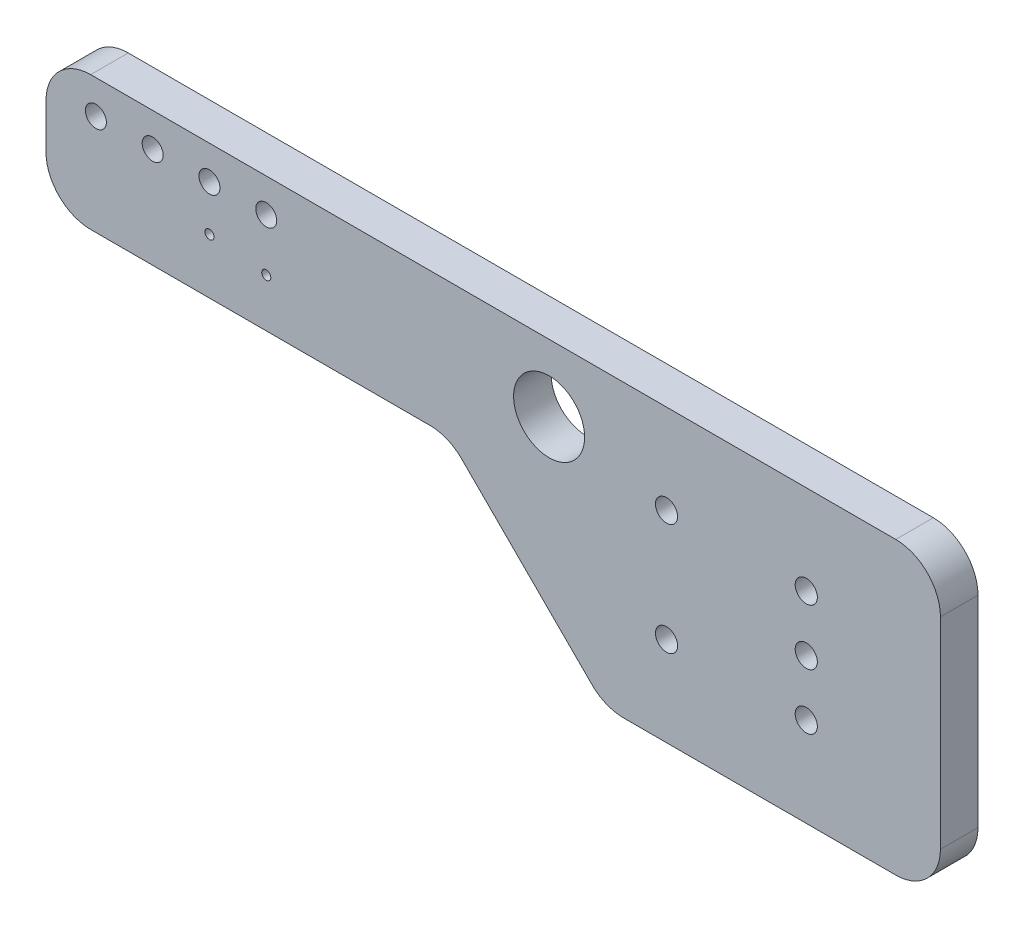
from build123d import *

# Parameters (mm, degrees)
BOARD_DEPTH        = 1.68
SKETCH2_R          = 0.2032
SKETCH2_R_2        = 0.4699
SKETCH2_R_3        = 1.5875
SKETCH2_R_4        = 0.4953
PLATED_HOLES_DEPTH = 2.68


with BuildPart() as part:
    # Sketch1 → BOARD (new body)
    with BuildSketch(Plane.XY):
        with BuildLine():
            Line((60, 63), (60, 61))
            ThreePointArc((60, 61), (60.585786438, 59.585786438), (62, 59))
            Line((62, 59), (77.171572667, 59))
            ThreePointArc((77.171572667, 59), (77.936939773, 58.847758994), (78.585786667, 58.414213333))
            Line((78.585786667, 58.414213333), (84.414213333, 52.585786667))
            ThreePointArc((84.414213333, 52.585786667), (85.063060227, 52.152241006), (85.828427333, 52))
            Line((85.828427333, 52), (98, 52))
            ThreePointArc((98, 52), (99.414213562, 52.585786438), (100, 54))
            Line((100, 54), (100, 63))
            ThreePointArc((100, 63), (99.414213562, 64.414213562), (98, 65))
            Line((98, 65), (62, 65))
            ThreePointArc((62, 65), (60.585786438, 64.414213562), (60, 63))
        make_face()
    extrude(amount=BOARD_DEPTH)

    # Sketch2 → PLATED HOLES (cut, through all)
    with BuildSketch(Plane.XY):
        with Locations((67.31, 61.468)):
            Circle(SKETCH2_R)
        with Locations((62.23, 63.5)):
            Circle(SKETCH2_R_2)
        with Locations((64.77, 63.5)):
            Circle(SKETCH2_R_2)
        with Locations((67.31, 63.5)):
            Circle(SKETCH2_R_2)
        with Locations((69.85, 61.1632)):
            Circle(SKETCH2_R)
        with Locations((69.85, 63.5)):
            Circle(SKETCH2_R_2)
        with Locations((82.499999998, 62.000000003)):
            Circle(SKETCH2_R_3)
        with Locations((87.749999989, 55.999999989)):
            Circle(SKETCH2_R_4)
        with Locations((87.749999989, 60.999999996)):
            Circle(SKETCH2_R_4)
        with Locations((94.000000011, 58.499999992)):
            Circle(SKETCH2_R_4)
        with Locations((94.000000011, 55.999999989)):
            Circle(SKETCH2_R_4)
        with Locations((94.000000011, 60.999999996)):
            Circle(SKETCH2_R_4)
    extrude(amount=PLATED_HOLES_DEPTH, mode=Mode.SUBTRACT)


solid = part.part
